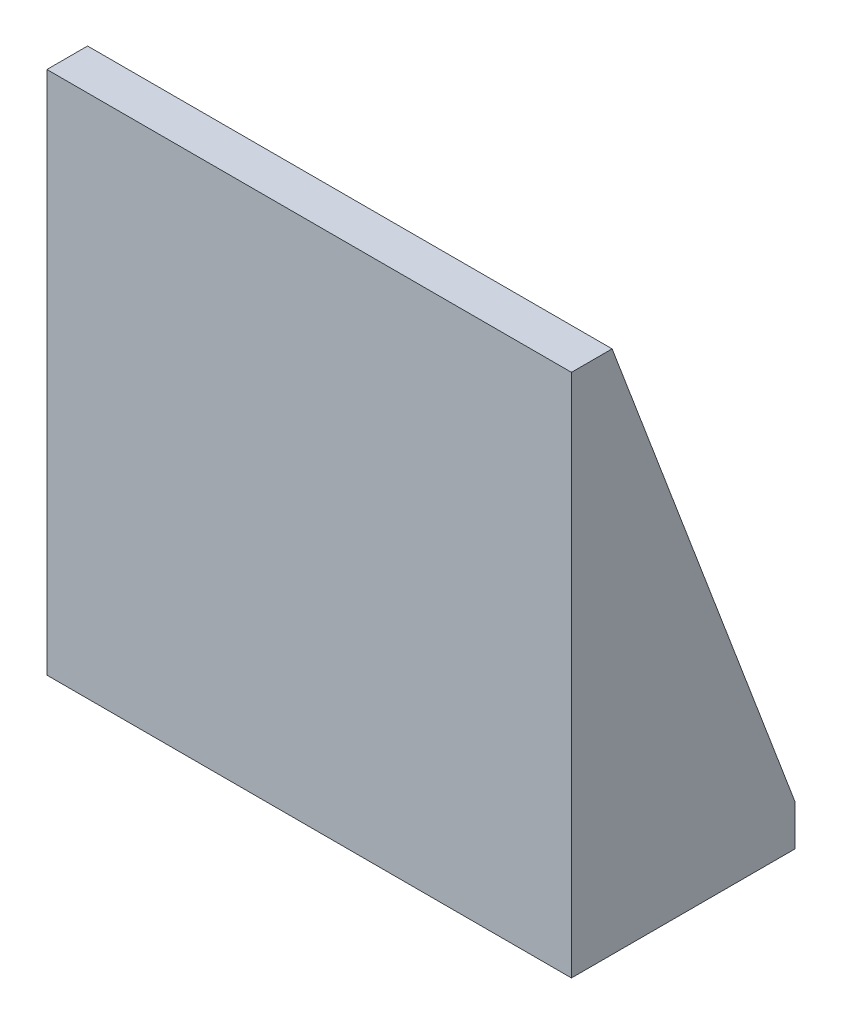
from build123d import *

# Parameters (mm, degrees)
EXTRUDE_THIN1_DEPTH = 64.5
EXTRUDE1_DEPTH      = 10


with BuildPart() as part:
    # Sketch1 → Extrude-Thin1 (new body, symmetric)
    with BuildSketch(Plane(origin=(0, 0, 0), x_dir=(0, 0, -1), z_dir=(1, 0, 0))):
        Polygon((0, 129), (0, 0), (55, 0), (55, 10), (10, 10), (10, 129), align=None)
    extrude(amount=EXTRUDE_THIN1_DEPTH, both=True)

    # Sketch2 → Extrude1 (add)
    with BuildSketch(Plane(origin=(64.5, 0, 0), x_dir=(0, 0, -1), z_dir=(1, 0, 0))):
        Polygon((10, 129), (55, 10), (10, 10), align=None)
    extrude1 = extrude(amount=-EXTRUDE1_DEPTH)

    # Mirror1: Extrude1 across plane
    add(extrude1.mirror(Plane(origin=(0, 0, 0), x_dir=(0, 0, 1), z_dir=(1, 0, 0))))


solid = part.part
